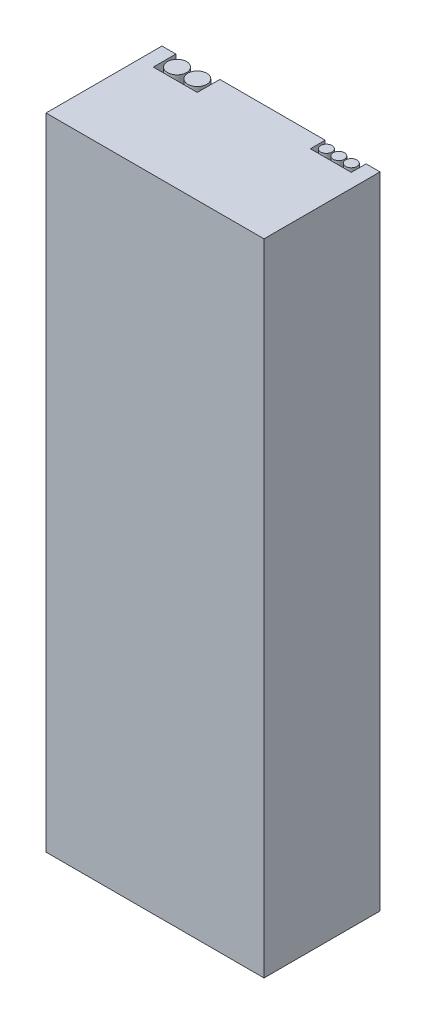
from build123d import *

# Parameters (mm, degrees)
SKETCH1_W           = 47
SKETCH1_H           = 25
BOSS_EXTRUDE1_DEPTH = 138
SKETCH2_W           = 9.48
SKETCH2_H           = 4.865
SKETCH2_R           = 2.0575
SKETCH2_W_2         = 8.82
SKETCH2_H_2         = 3.19
SKETCH2_R_2         = 1.22
CUT_EXTRUDE1_DEPTH  = 7


with BuildPart() as part:
    # Sketch1 → Boss-Extrude1 (new body)
    with BuildSketch(Plane(origin=(0, 0, 0), x_dir=(1, 0, 0), z_dir=(0, 1, 0))):
        with Locations((23.5, 12.5)):
            Rectangle(SKETCH1_W, SKETCH1_H)
    extrude(amount=BOSS_EXTRUDE1_DEPTH)

    # Sketch2 → Cut-Extrude1 (cut)
    with BuildSketch(Plane(origin=(0, 138, 0), x_dir=(1, 0, 0), z_dir=(0, 1, 0))):
        with Locations((7.74, 22.5675)):
            Rectangle(SKETCH2_W, SKETCH2_H)
        with Locations((5.5575, 22.6925)):
            Circle(SKETCH2_R, mode=Mode.SUBTRACT)
        with Locations((9.9225, 22.6925)):
            Circle(SKETCH2_R, mode=Mode.SUBTRACT)
        with Locations((39.59, 23.405)):
            Rectangle(SKETCH2_W_2, SKETCH2_H_2)
        with Locations((36.9, 23.53)):
            Circle(SKETCH2_R_2, mode=Mode.SUBTRACT)
        with Locations((39.59, 23.53)):
            Circle(SKETCH2_R_2, mode=Mode.SUBTRACT)
        with Locations((42.28, 23.53)):
            Circle(SKETCH2_R_2, mode=Mode.SUBTRACT)
    extrude(amount=-CUT_EXTRUDE1_DEPTH, mode=Mode.SUBTRACT)


solid = part.part
